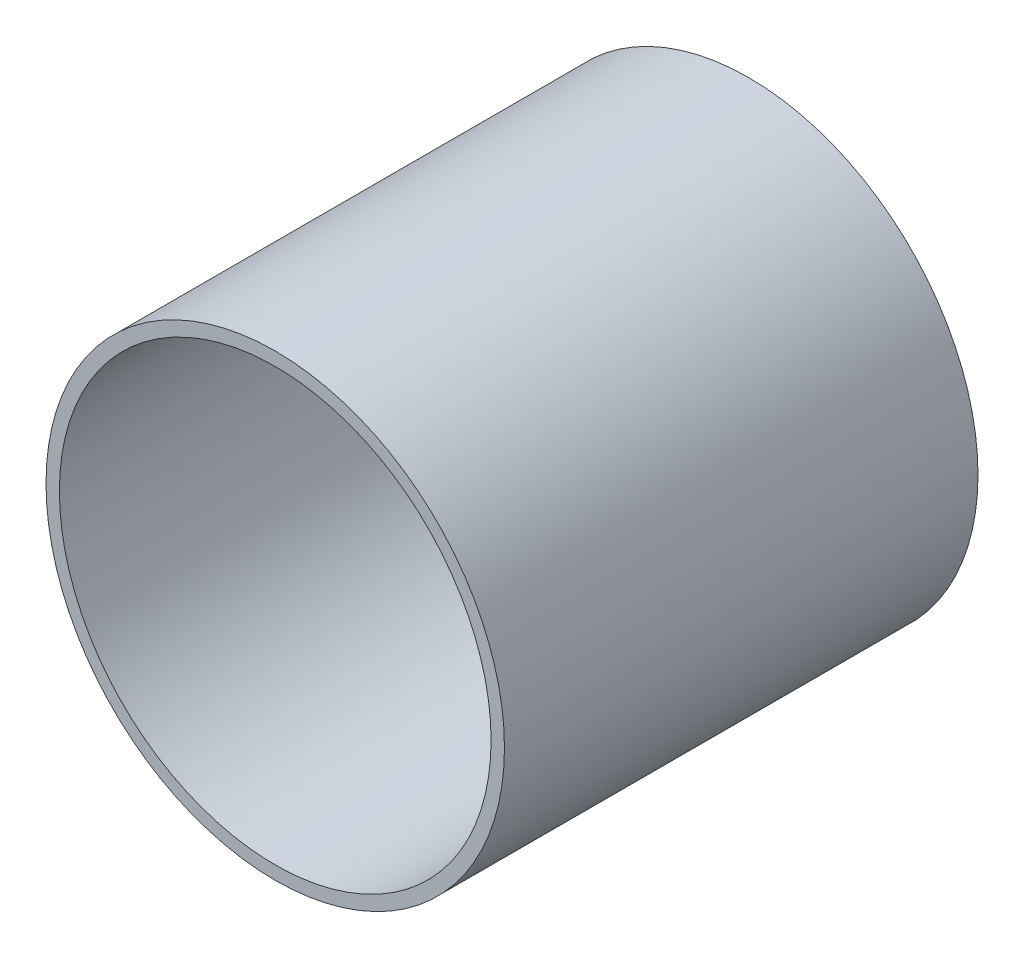
from build123d import *

# Parameters (mm, degrees)
SKETCH1_R           = 34.25
SKETCH1_R_2         = 32.25
BOSS_EXTRUDE1_DEPTH = 70.75


with BuildPart() as part:
    # Sketch1 → Boss-Extrude1 (new body)
    with BuildSketch(Plane.XY):
        Circle(SKETCH1_R)
        Circle(SKETCH1_R_2, mode=Mode.SUBTRACT)
    extrude(amount=BOSS_EXTRUDE1_DEPTH)


solid = part.part
